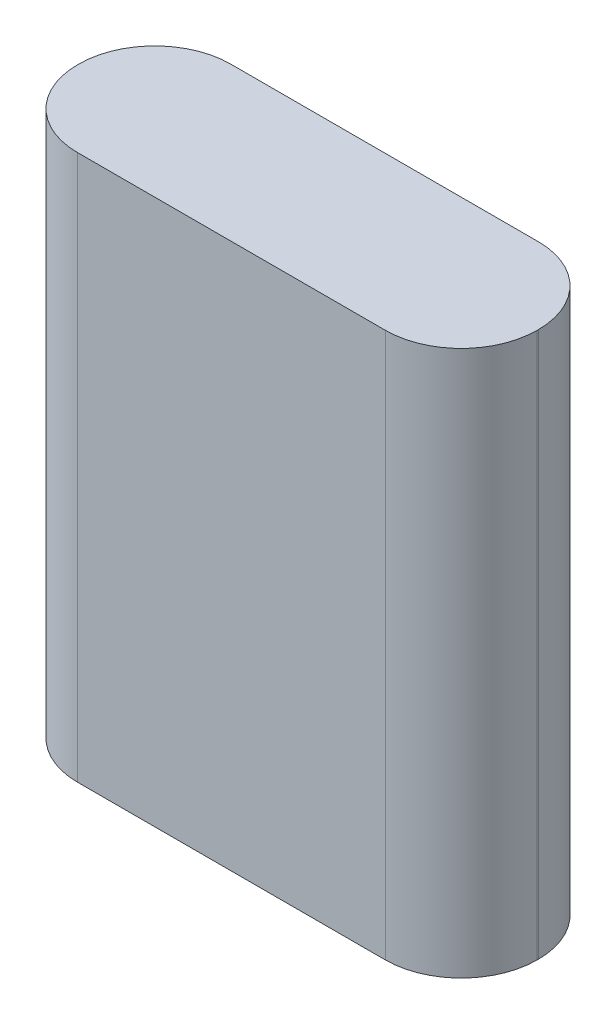
from build123d import *

# Parameters (mm, degrees)
SKETCH1_W           = 43
SKETCH1_H           = 14.33
BOSS_EXTRUDE1_DEPTH = 51
FILLET1_R           = 7.1


with BuildPart() as part:
    # Sketch1 → Boss-Extrude1 (new body)
    with BuildSketch(Plane(origin=(0, 0, 0), x_dir=(1, 0, 0), z_dir=(0, 1, 0))):
        Rectangle(SKETCH1_W, SKETCH1_H)
    extrude(amount=BOSS_EXTRUDE1_DEPTH)

    # Fillet1
    fillet1_edges = [part.edges().sort_by_distance(p)[0] for p in [
        (21.5, 25.5, 7.165),
        (-21.5, 25.5, 7.165),
        (-21.5, 25.5, -7.165),
        (21.5, 25.5, -7.165),
    ]]
    fillet(fillet1_edges, radius=FILLET1_R)


solid = part.part
